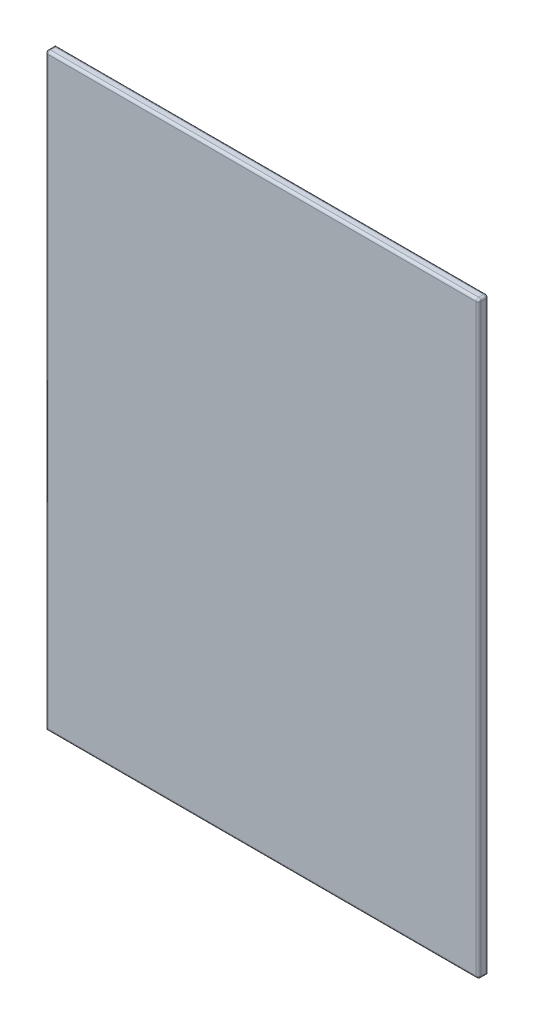
from build123d import *

# Parameters (mm, degrees)
SKETCH1_W           = 875
SKETCH1_H           = 1190
BOSS_EXTRUDE1_DEPTH = 20
FILLET1_R           = 5


with BuildPart() as part:
    # Sketch1 → Boss-Extrude1 (new body)
    with BuildSketch(Plane.XY):
        Rectangle(SKETCH1_W, SKETCH1_H)
    extrude(amount=BOSS_EXTRUDE1_DEPTH)

    # Fillet1
    fillet1_edges = [part.edges().sort_by_distance(p)[0] for p in [
        (-437.5, 0, 20),
        (0, -595, 20),
        (437.5, 0, 20),
        (0, 595, 0),
        (437.5, 0, 0),
        (437.5, -595, 10),
        (-437.5, 595, 10),
        (437.5, 595, 10),
        (0, 595, 20),
    ]]
    fillet(fillet1_edges, radius=FILLET1_R)


solid = part.part
